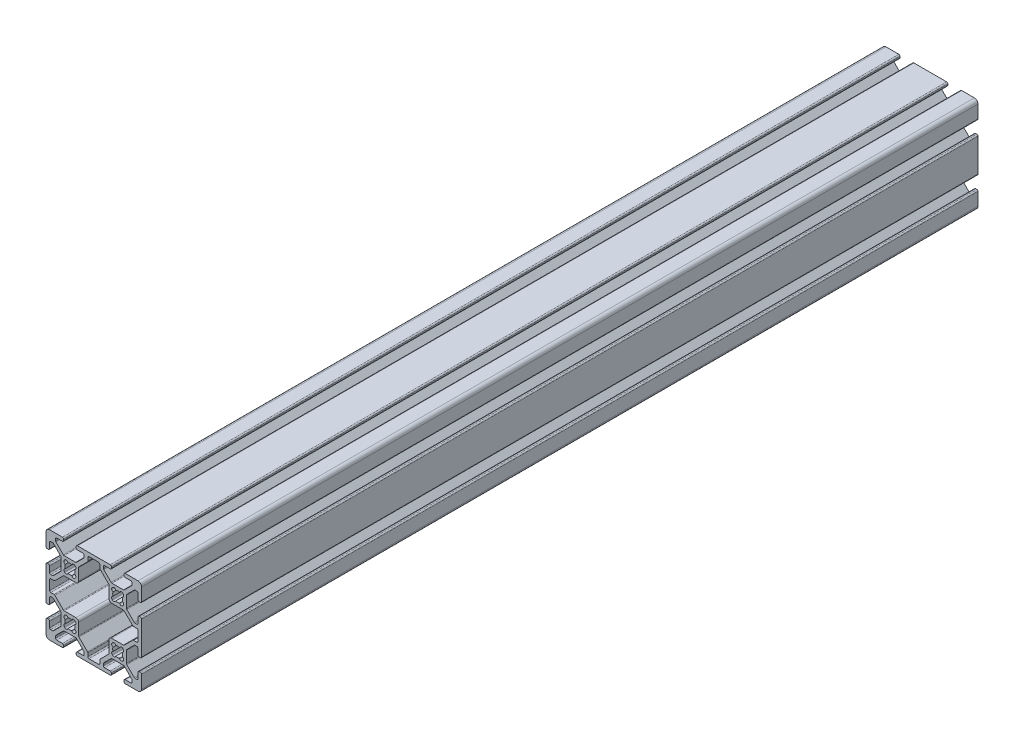
from build123d import *

# Parameters (mm, degrees)
EXTRUDE1_DEPTH = 350


with BuildPart() as part:
    # Sketch1 → Extrude1 (new body)
    with BuildSketch(Plane.XY):
        with BuildLine():
            Line((-22.383919339, -3.655), (-17.616080661, -3.655))
            ThreePointArc((-17.616080661, -3.655), (-17.421677478, -3.693669197), (-17.256870417, -3.803789755))
            Line((-17.256870417, -3.803789755), (-14.153789755, -6.906870417))
            ThreePointArc((-14.153789755, -6.906870417), (-14.043669197, -7.071677478), (-14.005, -7.266080661))
            Line((-14.005, -7.266080661), (-14.005, -7.992))
            ThreePointArc((-14.005, -7.992), (-14.153789755, -8.351210245), (-14.513, -8.5))
            Line((-14.513, -8.5), (-16.862, -8.5))
            ThreePointArc((-16.862, -8.5), (-17.221210245, -8.648789755), (-17.37, -9.008))
            Line((-17.37, -9.008), (-17.37, -9.492))
            ThreePointArc((-17.37, -9.492), (-17.221210245, -9.851210245), (-16.862, -10))
            Line((-16.862, -10), (-3.138, -10))
            ThreePointArc((-3.138, -10), (-2.778789755, -9.851210245), (-2.63, -9.492))
            Line((-2.63, -9.492), (-2.63, -9.008))
            ThreePointArc((-2.63, -9.008), (-2.778789755, -8.648789755), (-3.138, -8.5))
            Line((-3.138, -8.5), (-5.487, -8.5))
            ThreePointArc((-5.487, -8.5), (-5.846210245, -8.351210245), (-5.995, -7.992))
            Line((-5.995, -7.992), (-5.995, -7.266080661))
            ThreePointArc((-5.995, -7.266080661), (-5.956330803, -7.071677478), (-5.846210245, -6.906870417))
            Line((-5.846210245, -6.906870417), (-2.743129583, -3.803789755))
            ThreePointArc((-2.743129583, -3.803789755), (-2.578322522, -3.693669197), (-2.383919339, -3.655))
            Line((-2.383919339, -3.655), (2.383919339, -3.655))
            ThreePointArc((2.383919339, -3.655), (2.578322522, -3.693669197), (2.743129583, -3.803789755))
            Line((2.743129583, -3.803789755), (5.846210245, -6.906870417))
            ThreePointArc((5.846210245, -6.906870417), (5.956330803, -7.071677478), (5.995, -7.266080661))
            Line((5.995, -7.266080661), (5.995, -7.992))
            ThreePointArc((5.995, -7.992), (5.846210245, -8.351210245), (5.487, -8.5))
            Line((5.487, -8.5), (3.138, -8.5))
            ThreePointArc((3.138, -8.5), (2.778789755, -8.648789755), (2.63, -9.008))
            Line((2.63, -9.008), (2.63, -9.492))
            ThreePointArc((2.63, -9.492), (2.778789755, -9.851210245), (3.138, -10))
            Line((3.138, -10), (8.5, -10))
            ThreePointArc((8.5, -10), (9.560660172, -9.560660172), (10, -8.5))
            Line((10, -8.5), (10, -3.138))
            ThreePointArc((10, -3.138), (9.851210245, -2.778789755), (9.492, -2.63))
            Line((9.492, -2.63), (9.008, -2.63))
            ThreePointArc((9.008, -2.63), (8.648789755, -2.778789755), (8.5, -3.138))
            Line((8.5, -3.138), (8.5, -5.487))
            ThreePointArc((8.5, -5.487), (8.351210245, -5.846210245), (7.992, -5.995))
            Line((7.992, -5.995), (7.266080661, -5.995))
            ThreePointArc((7.266080661, -5.995), (7.071677478, -5.956330803), (6.906870417, -5.846210245))
            Line((6.906870417, -5.846210245), (3.803789755, -2.743129583))
            ThreePointArc((3.803789755, -2.743129583), (3.693669197, -2.578322522), (3.655, -2.383919339))
            Line((3.655, -2.383919339), (3.655, 2.383919339))
            ThreePointArc((3.655, 2.383919339), (3.693669197, 2.578322522), (3.803789755, 2.743129583))
            Line((3.803789755, 2.743129583), (6.906870417, 5.846210245))
            ThreePointArc((6.906870417, 5.846210245), (7.071677478, 5.956330803), (7.266080661, 5.995))
            Line((7.266080661, 5.995), (7.992, 5.995))
            ThreePointArc((7.992, 5.995), (8.351210245, 5.846210245), (8.5, 5.487))
            Line((8.5, 5.487), (8.5, 3.138))
            ThreePointArc((8.5, 3.138), (8.648789755, 2.778789755), (9.008, 2.63))
            Line((9.008, 2.63), (9.492, 2.63))
            ThreePointArc((9.492, 2.63), (9.851210245, 2.778789755), (10, 3.138))
            Line((10, 3.138), (10, 16.862))
            ThreePointArc((10, 16.862), (9.851210245, 17.221210245), (9.492, 17.37))
            Line((9.492, 17.37), (9.008, 17.37))
            ThreePointArc((9.008, 17.37), (8.648789755, 17.221210245), (8.5, 16.862))
            Line((8.5, 16.862), (8.5, 14.513))
            ThreePointArc((8.5, 14.513), (8.351210245, 14.153789755), (7.992, 14.005))
            Line((7.992, 14.005), (7.266080661, 14.005))
            ThreePointArc((7.266080661, 14.005), (7.071677478, 14.043669197), (6.906870417, 14.153789755))
            Line((6.906870417, 14.153789755), (3.803789755, 17.256870417))
            ThreePointArc((3.803789755, 17.256870417), (3.693669197, 17.421677478), (3.655, 17.616080661))
            Line((3.655, 17.616080661), (3.655, 22.383919339))
            ThreePointArc((3.655, 22.383919339), (3.693669197, 22.578322522), (3.803789755, 22.743129583))
            Line((3.803789755, 22.743129583), (6.906870417, 25.846210245))
            ThreePointArc((6.906870417, 25.846210245), (7.071677478, 25.956330803), (7.266080661, 25.995))
            Line((7.266080661, 25.995), (7.992, 25.995))
            ThreePointArc((7.992, 25.995), (8.351210245, 25.846210245), (8.5, 25.487))
            Line((8.5, 25.487), (8.5, 23.138))
            ThreePointArc((8.5, 23.138), (8.648789755, 22.778789755), (9.008, 22.63))
            Line((9.008, 22.63), (9.492, 22.63))
            ThreePointArc((9.492, 22.63), (9.851210245, 22.778789755), (10, 23.138))
            Line((10, 23.138), (10, 28.5))
            ThreePointArc((10, 28.5), (9.560660172, 29.560660172), (8.5, 30))
            Line((8.5, 30), (3.138, 30))
            ThreePointArc((3.138, 30), (2.778789755, 29.851210245), (2.63, 29.492))
            Line((2.63, 29.492), (2.63, 29.008))
            ThreePointArc((2.63, 29.008), (2.778789755, 28.648789755), (3.138, 28.5))
            Line((3.138, 28.5), (5.487, 28.5))
            ThreePointArc((5.487, 28.5), (5.846210245, 28.351210245), (5.995, 27.992))
            Line((5.995, 27.992), (5.995, 27.266080661))
            ThreePointArc((5.995, 27.266080661), (5.956330803, 27.071677478), (5.846210245, 26.906870417))
            Line((5.846210245, 26.906870417), (2.743129583, 23.803789755))
            ThreePointArc((2.743129583, 23.803789755), (2.578322522, 23.693669197), (2.383919339, 23.655))
            Line((2.383919339, 23.655), (-2.383919339, 23.655))
            ThreePointArc((-2.383919339, 23.655), (-2.578322522, 23.693669197), (-2.743129583, 23.803789755))
            Line((-2.743129583, 23.803789755), (-5.846210245, 26.906870417))
            ThreePointArc((-5.846210245, 26.906870417), (-5.956330803, 27.071677478), (-5.995, 27.266080661))
            Line((-5.995, 27.266080661), (-5.995, 27.992))
            ThreePointArc((-5.995, 27.992), (-5.846210245, 28.351210245), (-5.487, 28.5))
            Line((-5.487, 28.5), (-3.138, 28.5))
            ThreePointArc((-3.138, 28.5), (-2.778789755, 28.648789755), (-2.63, 29.008))
            Line((-2.63, 29.008), (-2.63, 29.492))
            ThreePointArc((-2.63, 29.492), (-2.778789755, 29.851210245), (-3.138, 30))
            Line((-3.138, 30), (-16.862, 30))
            ThreePointArc((-16.862, 30), (-17.221210245, 29.851210245), (-17.37, 29.492))
            Line((-17.37, 29.492), (-17.37, 29.008))
            ThreePointArc((-17.37, 29.008), (-17.221210245, 28.648789755), (-16.862, 28.5))
            Line((-16.862, 28.5), (-14.513, 28.5))
            ThreePointArc((-14.513, 28.5), (-14.153789755, 28.351210245), (-14.005, 27.992))
            Line((-14.005, 27.992), (-14.005, 27.266080661))
            ThreePointArc((-14.005, 27.266080661), (-14.043669197, 27.071677478), (-14.153789755, 26.906870417))
            Line((-14.153789755, 26.906870417), (-17.256870417, 23.803789755))
            ThreePointArc((-17.256870417, 23.803789755), (-17.421677478, 23.693669197), (-17.616080661, 23.655))
            Line((-17.616080661, 23.655), (-22.383919339, 23.655))
            ThreePointArc((-22.383919339, 23.655), (-22.578322522, 23.693669197), (-22.743129583, 23.803789755))
            Line((-22.743129583, 23.803789755), (-25.846210245, 26.906870417))
            ThreePointArc((-25.846210245, 26.906870417), (-25.956330803, 27.071677478), (-25.995, 27.266080661))
            Line((-25.995, 27.266080661), (-25.995, 27.992))
            ThreePointArc((-25.995, 27.992), (-25.846210245, 28.351210245), (-25.487, 28.5))
            Line((-25.487, 28.5), (-23.138, 28.5))
            ThreePointArc((-23.138, 28.5), (-22.778789755, 28.648789755), (-22.63, 29.008))
            Line((-22.63, 29.008), (-22.63, 29.492))
            ThreePointArc((-22.63, 29.492), (-22.778789755, 29.851210245), (-23.138, 30))
            Line((-23.138, 30), (-28.5, 30))
            ThreePointArc((-28.5, 30), (-29.560660172, 29.560660172), (-30, 28.5))
            Line((-30, 28.5), (-30, 23.138))
            ThreePointArc((-30, 23.138), (-29.851210245, 22.778789755), (-29.492, 22.63))
            Line((-29.492, 22.63), (-29.008, 22.63))
            ThreePointArc((-29.008, 22.63), (-28.648789755, 22.778789755), (-28.5, 23.138))
            Line((-28.5, 23.138), (-28.5, 25.487))
            ThreePointArc((-28.5, 25.487), (-28.351210245, 25.846210245), (-27.992, 25.995))
            Line((-27.992, 25.995), (-27.266080661, 25.995))
            ThreePointArc((-27.266080661, 25.995), (-27.071677478, 25.956330803), (-26.906870417, 25.846210245))
            Line((-26.906870417, 25.846210245), (-23.803789755, 22.743129583))
            ThreePointArc((-23.803789755, 22.743129583), (-23.693669197, 22.578322522), (-23.655, 22.383919339))
            Line((-23.655, 22.383919339), (-23.655, 17.616080661))
            ThreePointArc((-23.655, 17.616080661), (-23.693669197, 17.421677478), (-23.803789755, 17.256870417))
            Line((-23.803789755, 17.256870417), (-26.906870417, 14.153789755))
            ThreePointArc((-26.906870417, 14.153789755), (-27.071677478, 14.043669197), (-27.266080661, 14.005))
            Line((-27.266080661, 14.005), (-27.992, 14.005))
            ThreePointArc((-27.992, 14.005), (-28.351210245, 14.153789755), (-28.5, 14.513))
            Line((-28.5, 14.513), (-28.5, 16.862))
            ThreePointArc((-28.5, 16.862), (-28.648789755, 17.221210245), (-29.008, 17.37))
            Line((-29.008, 17.37), (-29.492, 17.37))
            ThreePointArc((-29.492, 17.37), (-29.851210245, 17.221210245), (-30, 16.862))
            Line((-30, 16.862), (-30, 3.138))
            ThreePointArc((-30, 3.138), (-29.851210245, 2.778789755), (-29.492, 2.63))
            Line((-29.492, 2.63), (-29.008, 2.63))
            ThreePointArc((-29.008, 2.63), (-28.648789755, 2.778789755), (-28.5, 3.138))
            Line((-28.5, 3.138), (-28.5, 5.487))
            ThreePointArc((-28.5, 5.487), (-28.351210245, 5.846210245), (-27.992, 5.995))
            Line((-27.992, 5.995), (-27.266080661, 5.995))
            ThreePointArc((-27.266080661, 5.995), (-27.071677478, 5.956330803), (-26.906870417, 5.846210245))
            Line((-26.906870417, 5.846210245), (-23.803789755, 2.743129583))
            ThreePointArc((-23.803789755, 2.743129583), (-23.693669197, 2.578322522), (-23.655, 2.383919339))
            Line((-23.655, 2.383919339), (-23.655, -2.383919339))
            ThreePointArc((-23.655, -2.383919339), (-23.693669197, -2.578322522), (-23.803789755, -2.743129583))
            Line((-23.803789755, -2.743129583), (-26.906870417, -5.846210245))
            ThreePointArc((-26.906870417, -5.846210245), (-27.071677478, -5.956330803), (-27.266080661, -5.995))
            Line((-27.266080661, -5.995), (-27.992, -5.995))
            ThreePointArc((-27.992, -5.995), (-28.351210245, -5.846210245), (-28.5, -5.487))
            Line((-28.5, -5.487), (-28.5, -3.138))
            ThreePointArc((-28.5, -3.138), (-28.648789755, -2.778789755), (-29.008, -2.63))
            Line((-29.008, -2.63), (-29.492, -2.63))
            ThreePointArc((-29.492, -2.63), (-29.851210245, -2.778789755), (-30, -3.138))
            Line((-30, -3.138), (-30, -8.5))
            ThreePointArc((-30, -8.5), (-29.560660172, -9.560660172), (-28.5, -10))
            Line((-28.5, -10), (-23.138, -10))
            ThreePointArc((-23.138, -10), (-22.778789755, -9.851210245), (-22.63, -9.492))
            Line((-22.63, -9.492), (-22.63, -9.008))
            ThreePointArc((-22.63, -9.008), (-22.778789755, -8.648789755), (-23.138, -8.5))
            Line((-23.138, -8.5), (-25.487, -8.5))
            ThreePointArc((-25.487, -8.5), (-25.846210245, -8.351210245), (-25.995, -7.992))
            Line((-25.995, -7.992), (-25.995, -7.266080661))
            ThreePointArc((-25.995, -7.266080661), (-25.956330803, -7.071677478), (-25.846210245, -6.906870417))
            Line((-25.846210245, -6.906870417), (-22.743129583, -3.803789755))
            ThreePointArc((-22.743129583, -3.803789755), (-22.578322522, -3.693669197), (-22.383919339, -3.655))
        make_face()
        with BuildLine():
            Line((-2.124900844, 17.695494034), (-2.304505966, 17.875099156))
            ThreePointArc((-2.304505966, 17.875099156), (-2.505938017, 18.643532189), (-1.935133506, 19.196023282))
            ThreePointArc((-1.935133506, 19.196023282), (-2.0955, 20), (-1.935133506, 20.803976718))
            ThreePointArc((-1.935133506, 20.803976718), (-2.505938017, 21.356467811), (-2.304505966, 22.124900844))
            Line((-2.304505966, 22.124900844), (-2.124900844, 22.304505966))
            ThreePointArc((-2.124900844, 22.304505966), (-1.356467811, 22.505938017), (-0.803976718, 21.935133506))
            ThreePointArc((-0.803976718, 21.935133506), (0, 22.0955), (0.803976718, 21.935133506))
            ThreePointArc((0.803976718, 21.935133506), (1.356467811, 22.505938017), (2.124900844, 22.304505966))
            Line((2.124900844, 22.304505966), (2.304505966, 22.124900844))
            ThreePointArc((2.304505966, 22.124900844), (2.505938017, 21.356467811), (1.935133506, 20.803976718))
            ThreePointArc((1.935133506, 20.803976718), (2.0955, 20), (1.935133506, 19.196023282))
            ThreePointArc((1.935133506, 19.196023282), (2.505938017, 18.643532189), (2.304505966, 17.875099156))
            Line((2.304505966, 17.875099156), (2.124900844, 17.695494034))
            ThreePointArc((2.124900844, 17.695494034), (1.356467811, 17.494061983), (0.803976718, 18.064866494))
            ThreePointArc((0.803976718, 18.064866494), (0, 17.9045), (-0.803976718, 18.064866494))
            ThreePointArc((-0.803976718, 18.064866494), (-1.356467811, 17.494061983), (-2.124900844, 17.695494034))
        make_face(mode=Mode.SUBTRACT)
        with BuildLine():
            Line((-22.124900844, 17.695494034), (-22.304505966, 17.875099156))
            ThreePointArc((-22.304505966, 17.875099156), (-22.505938017, 18.643532189), (-21.935133506, 19.196023282))
            ThreePointArc((-21.935133506, 19.196023282), (-22.0955, 20), (-21.935133506, 20.803976718))
            ThreePointArc((-21.935133506, 20.803976718), (-22.505938017, 21.356467811), (-22.304505966, 22.124900844))
            Line((-22.304505966, 22.124900844), (-22.124900844, 22.304505966))
            ThreePointArc((-22.124900844, 22.304505966), (-21.356467811, 22.505938017), (-20.803976718, 21.935133506))
            ThreePointArc((-20.803976718, 21.935133506), (-20, 22.0955), (-19.196023282, 21.935133506))
            ThreePointArc((-19.196023282, 21.935133506), (-18.643532189, 22.505938017), (-17.875099156, 22.304505966))
            Line((-17.875099156, 22.304505966), (-17.695494034, 22.124900844))
            ThreePointArc((-17.695494034, 22.124900844), (-17.494061983, 21.356467811), (-18.064866494, 20.803976718))
            ThreePointArc((-18.064866494, 20.803976718), (-17.9045, 20), (-18.064866494, 19.196023282))
            ThreePointArc((-18.064866494, 19.196023282), (-17.494061983, 18.643532189), (-17.695494034, 17.875099156))
            Line((-17.695494034, 17.875099156), (-17.875099156, 17.695494034))
            ThreePointArc((-17.875099156, 17.695494034), (-18.643532189, 17.494061983), (-19.196023282, 18.064866494))
            ThreePointArc((-19.196023282, 18.064866494), (-20, 17.9045), (-20.803976718, 18.064866494))
            ThreePointArc((-20.803976718, 18.064866494), (-21.356467811, 17.494061983), (-22.124900844, 17.695494034))
        make_face(mode=Mode.SUBTRACT)
        with BuildLine():
            Line((-2.124900844, -2.304505966), (-2.304505966, -2.124900844))
            ThreePointArc((-2.304505966, -2.124900844), (-2.505938017, -1.356467811), (-1.935133506, -0.803976718))
            ThreePointArc((-1.935133506, -0.803976718), (-2.0955, 0), (-1.935133506, 0.803976718))
            ThreePointArc((-1.935133506, 0.803976718), (-2.505938017, 1.356467811), (-2.304505966, 2.124900844))
            Line((-2.304505966, 2.124900844), (-2.124900844, 2.304505966))
            ThreePointArc((-2.124900844, 2.304505966), (-1.356467811, 2.505938017), (-0.803976718, 1.935133506))
            ThreePointArc((-0.803976718, 1.935133506), (0, 2.0955), (0.803976718, 1.935133506))
            ThreePointArc((0.803976718, 1.935133506), (1.356467811, 2.505938017), (2.124900844, 2.304505966))
            Line((2.124900844, 2.304505966), (2.304505966, 2.124900844))
            ThreePointArc((2.304505966, 2.124900844), (2.505938017, 1.356467811), (1.935133506, 0.803976718))
            ThreePointArc((1.935133506, 0.803976718), (2.0955, 0), (1.935133506, -0.803976718))
            ThreePointArc((1.935133506, -0.803976718), (2.505938017, -1.356467811), (2.304505966, -2.124900844))
            Line((2.304505966, -2.124900844), (2.124900844, -2.304505966))
            ThreePointArc((2.124900844, -2.304505966), (1.356467811, -2.505938017), (0.803976718, -1.935133506))
            ThreePointArc((0.803976718, -1.935133506), (0, -2.0955), (-0.803976718, -1.935133506))
            ThreePointArc((-0.803976718, -1.935133506), (-1.356467811, -2.505938017), (-2.124900844, -2.304505966))
        make_face(mode=Mode.SUBTRACT)
        with BuildLine():
            Line((-12.505, -7.992), (-12.505, -6.644760318))
            ThreePointArc((-12.505, -6.644760318), (-12.543669197, -6.450357134), (-12.653789755, -6.285550073))
            Line((-12.653789755, -6.285550073), (-16.196210245, -2.743129583))
            ThreePointArc((-16.196210245, -2.743129583), (-16.306330803, -2.578322522), (-16.345, -2.383919339))
            Line((-16.345, -2.383919339), (-16.345, 2.512))
            ThreePointArc((-16.345, 2.512), (-16.679776949, 3.320223051), (-17.488, 3.655))
            Line((-17.488, 3.655), (-22.383919339, 3.655))
            ThreePointArc((-22.383919339, 3.655), (-22.578322522, 3.693669197), (-22.743129583, 3.803789755))
            Line((-22.743129583, 3.803789755), (-26.285550073, 7.346210245))
            ThreePointArc((-26.285550073, 7.346210245), (-26.450357134, 7.456330803), (-26.644760318, 7.495))
            Line((-26.644760318, 7.495), (-27.992, 7.495))
            ThreePointArc((-27.992, 7.495), (-28.351210245, 7.643789755), (-28.5, 8.003))
            Line((-28.5, 8.003), (-28.5, 11.997))
            ThreePointArc((-28.5, 11.997), (-28.351210245, 12.356210245), (-27.992, 12.505))
            Line((-27.992, 12.505), (-26.644760318, 12.505))
            ThreePointArc((-26.644760318, 12.505), (-26.450357134, 12.543669197), (-26.285550073, 12.653789755))
            Line((-26.285550073, 12.653789755), (-22.743129583, 16.196210245))
            ThreePointArc((-22.743129583, 16.196210245), (-22.578322522, 16.306330803), (-22.383919339, 16.345))
            Line((-22.383919339, 16.345), (-17.488, 16.345))
            ThreePointArc((-17.488, 16.345), (-16.679776949, 16.679776949), (-16.345, 17.488))
            Line((-16.345, 17.488), (-16.345, 22.383919339))
            ThreePointArc((-16.345, 22.383919339), (-16.306330803, 22.578322522), (-16.196210245, 22.743129583))
            Line((-16.196210245, 22.743129583), (-12.653789755, 26.285550073))
            ThreePointArc((-12.653789755, 26.285550073), (-12.543669197, 26.450357134), (-12.505, 26.644760318))
            Line((-12.505, 26.644760318), (-12.505, 27.992))
            ThreePointArc((-12.505, 27.992), (-12.356210245, 28.351210245), (-11.997, 28.5))
            Line((-11.997, 28.5), (-8.003, 28.5))
            ThreePointArc((-8.003, 28.5), (-7.643789755, 28.351210245), (-7.495, 27.992))
            Line((-7.495, 27.992), (-7.495, 26.644760318))
            ThreePointArc((-7.495, 26.644760318), (-7.456330803, 26.450357134), (-7.346210245, 26.285550073))
            Line((-7.346210245, 26.285550073), (-3.803789755, 22.743129583))
            ThreePointArc((-3.803789755, 22.743129583), (-3.693669197, 22.578322522), (-3.655, 22.383919339))
            Line((-3.655, 22.383919339), (-3.655, 17.488))
            ThreePointArc((-3.655, 17.488), (-3.320223051, 16.679776949), (-2.512, 16.345))
            Line((-2.512, 16.345), (2.383919339, 16.345))
            ThreePointArc((2.383919339, 16.345), (2.578322522, 16.306330803), (2.743129583, 16.196210245))
            Line((2.743129583, 16.196210245), (6.285550073, 12.653789755))
            ThreePointArc((6.285550073, 12.653789755), (6.450357134, 12.543669197), (6.644760318, 12.505))
            Line((6.644760318, 12.505), (7.992, 12.505))
            ThreePointArc((7.992, 12.505), (8.351210245, 12.356210245), (8.5, 11.997))
            Line((8.5, 11.997), (8.5, 8.003))
            ThreePointArc((8.5, 8.003), (8.351210245, 7.643789755), (7.992, 7.495))
            Line((7.992, 7.495), (6.644760318, 7.495))
            ThreePointArc((6.644760318, 7.495), (6.450357134, 7.456330803), (6.285550073, 7.346210245))
            Line((6.285550073, 7.346210245), (2.743129583, 3.803789755))
            ThreePointArc((2.743129583, 3.803789755), (2.578322522, 3.693669197), (2.383919339, 3.655))
            Line((2.383919339, 3.655), (-2.512, 3.655))
            ThreePointArc((-2.512, 3.655), (-3.320223051, 3.320223051), (-3.655, 2.512))
            Line((-3.655, 2.512), (-3.655, -2.383919339))
            ThreePointArc((-3.655, -2.383919339), (-3.693669197, -2.578322522), (-3.803789755, -2.743129583))
            Line((-3.803789755, -2.743129583), (-7.346210245, -6.285550073))
            ThreePointArc((-7.346210245, -6.285550073), (-7.456330803, -6.450357134), (-7.495, -6.644760318))
            Line((-7.495, -6.644760318), (-7.495, -7.992))
            ThreePointArc((-7.495, -7.992), (-7.643789755, -8.351210245), (-8.003, -8.5))
            Line((-8.003, -8.5), (-11.997, -8.5))
            ThreePointArc((-11.997, -8.5), (-12.356210245, -8.351210245), (-12.505, -7.992))
        make_face(mode=Mode.SUBTRACT)
        with BuildLine():
            Line((-22.124900844, -2.304505966), (-22.304505966, -2.124900844))
            ThreePointArc((-22.304505966, -2.124900844), (-22.505938017, -1.356467811), (-21.935133506, -0.803976718))
            ThreePointArc((-21.935133506, -0.803976718), (-22.0955, 0), (-21.935133506, 0.803976718))
            ThreePointArc((-21.935133506, 0.803976718), (-22.505938017, 1.356467811), (-22.304505966, 2.124900844))
            Line((-22.304505966, 2.124900844), (-22.124900844, 2.304505966))
            ThreePointArc((-22.124900844, 2.304505966), (-21.356467811, 2.505938017), (-20.803976718, 1.935133506))
            ThreePointArc((-20.803976718, 1.935133506), (-20, 2.0955), (-19.196023282, 1.935133506))
            ThreePointArc((-19.196023282, 1.935133506), (-18.643532189, 2.505938017), (-17.875099156, 2.304505966))
            Line((-17.875099156, 2.304505966), (-17.695494034, 2.124900844))
            ThreePointArc((-17.695494034, 2.124900844), (-17.494061983, 1.356467811), (-18.064866494, 0.803976718))
            ThreePointArc((-18.064866494, 0.803976718), (-17.9045, 0), (-18.064866494, -0.803976718))
            ThreePointArc((-18.064866494, -0.803976718), (-17.494061983, -1.356467811), (-17.695494034, -2.124900844))
            Line((-17.695494034, -2.124900844), (-17.875099156, -2.304505966))
            ThreePointArc((-17.875099156, -2.304505966), (-18.643532189, -2.505938017), (-19.196023282, -1.935133506))
            ThreePointArc((-19.196023282, -1.935133506), (-20, -2.0955), (-20.803976718, -1.935133506))
            ThreePointArc((-20.803976718, -1.935133506), (-21.356467811, -2.505938017), (-22.124900844, -2.304505966))
        make_face(mode=Mode.SUBTRACT)
    extrude(amount=-EXTRUDE1_DEPTH)


solid = part.part
